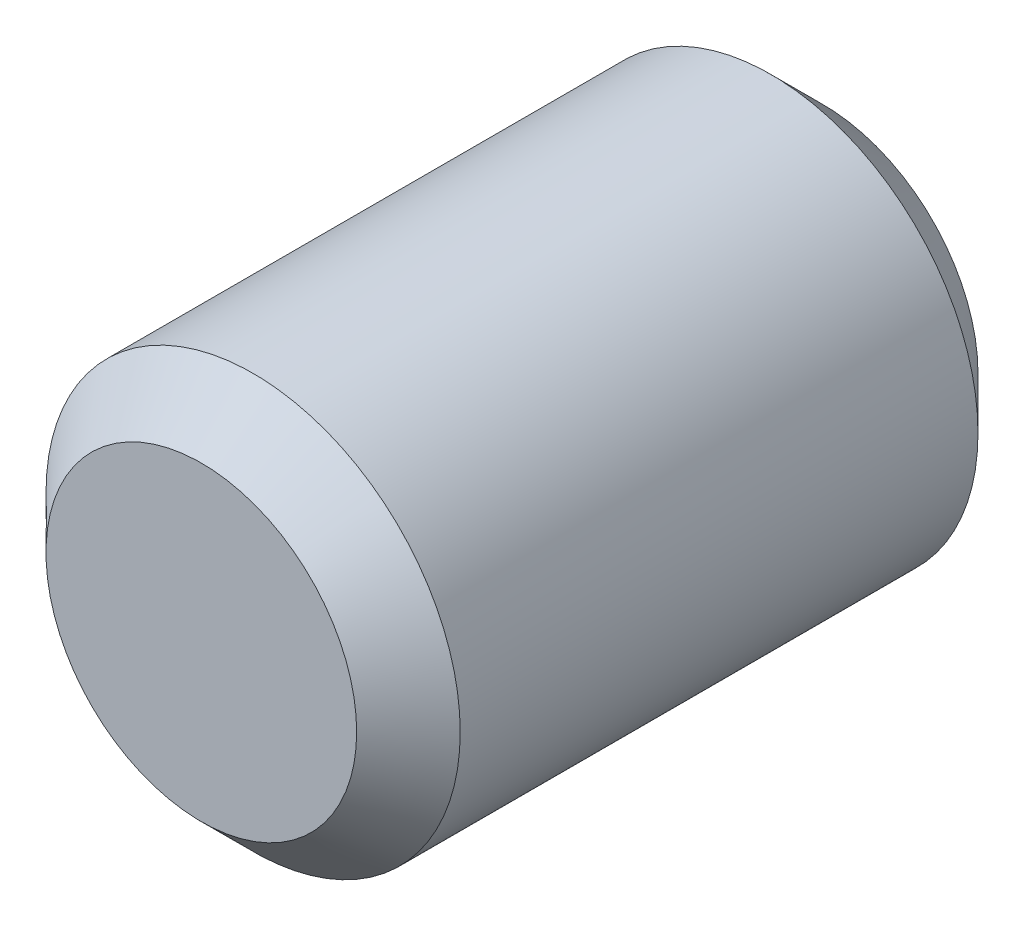
from build123d import *

# Parameters (mm, degrees)
SKETCH1_R           = 2
BOSS_EXTRUDE1_DEPTH = 6
CHAMFER1_SIZE       = 0.5


with BuildPart() as part:
    # Sketch1 → Boss-Extrude1 (new body)
    with BuildSketch(Plane.XY):
        Circle(SKETCH1_R)
    extrude(amount=BOSS_EXTRUDE1_DEPTH)

    # Chamfer1
    chamfer1_edges = [part.edges().sort_by_distance(p)[0] for p in [
        (-2, 0, 0),
        (-2, 0, 6),
    ]]
    chamfer(chamfer1_edges, length=CHAMFER1_SIZE)


solid = part.part
